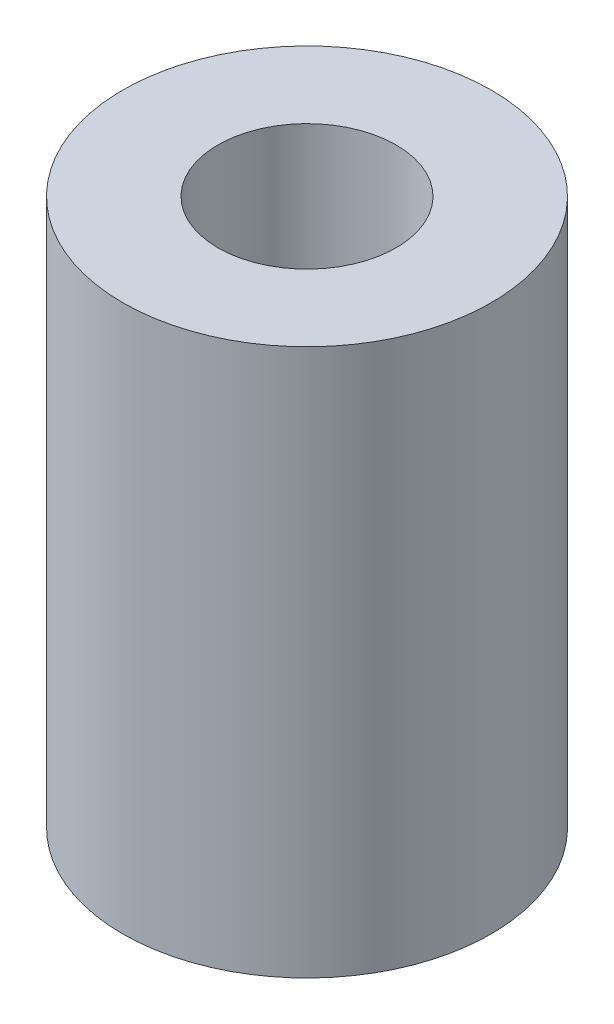
from build123d import *

# Parameters (mm, degrees)
SKETCH1_R           = 7.75
SKETCH1_R_2         = 3.75
BOSS_EXTRUDE1_DEPTH = 23


with BuildPart() as part:
    # Sketch1 → Boss-Extrude1 (new body)
    with BuildSketch(Plane(origin=(0, 0, 0), x_dir=(1, 0, 0), z_dir=(0, 1, 0))):
        Circle(SKETCH1_R)
        Circle(SKETCH1_R_2, mode=Mode.SUBTRACT)
    extrude(amount=BOSS_EXTRUDE1_DEPTH)


solid = part.part
